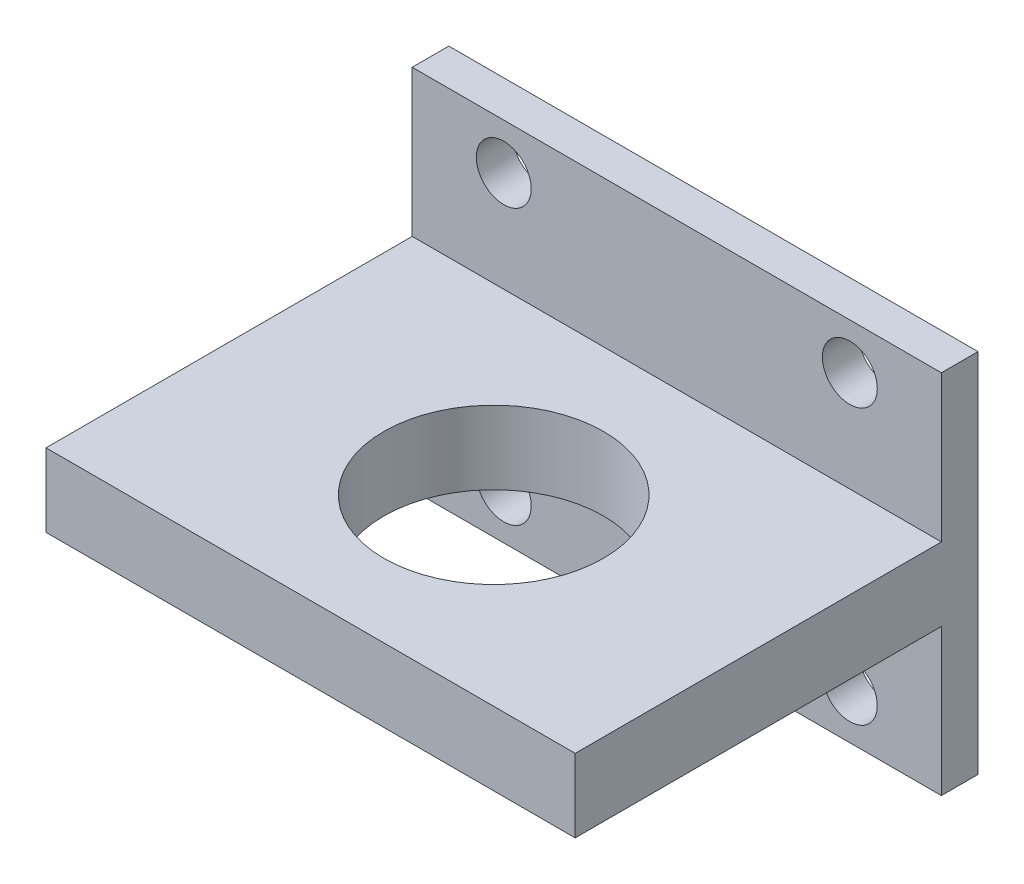
from build123d import *

# Parameters (mm, degrees)
SKETCH_1_W          = 28.9
SKETCH_1_H          = 20
SKETCH_1_R          = 1.5
EXTRUDE_1_DEPTH     = 2
EXTRUDE_2_DEPTH     = 20
SKETCH_4_R          = 6
CUT_EXTRUDE_1_DEPTH = 10


with BuildPart() as part:
    # 草图1 → 凸台-拉伸1 (new body)
    with BuildSketch(Plane.XY):
        with Locations((18.138262449, 35.158029485)):
            Rectangle(SKETCH_1_W, SKETCH_1_H)
        with Locations((27.588262449, 42.658029485)):
            Circle(SKETCH_1_R, mode=Mode.SUBTRACT)
        with Locations((8.688262449, 42.658029485)):
            Circle(SKETCH_1_R, mode=Mode.SUBTRACT)
        with Locations((8.688262449, 27.658029485)):
            Circle(SKETCH_1_R, mode=Mode.SUBTRACT)
        with Locations((27.588262449, 27.658029485)):
            Circle(SKETCH_1_R, mode=Mode.SUBTRACT)
    extrude(amount=EXTRUDE_1_DEPTH)

    # 草图2 → 凸台-拉伸2 (add)
    with BuildSketch(Plane.XY.offset(2)):
        Polygon((3.688262449, 35.158029485), (3.688262449, 37.158029485), (32.588262449, 37.158029485), (32.588262449, 33.158029485), (3.688262449, 33.158029485), align=None)
    extrude(amount=EXTRUDE_2_DEPTH)

    # 草图4 → 切除-拉伸1 (cut)
    with BuildSketch(Plane.XZ.offset(-33.158029485)):
        with Locations((18.138262449, 12)):
            Circle(SKETCH_4_R)
    extrude(amount=-CUT_EXTRUDE_1_DEPTH, mode=Mode.SUBTRACT)


solid = part.part
